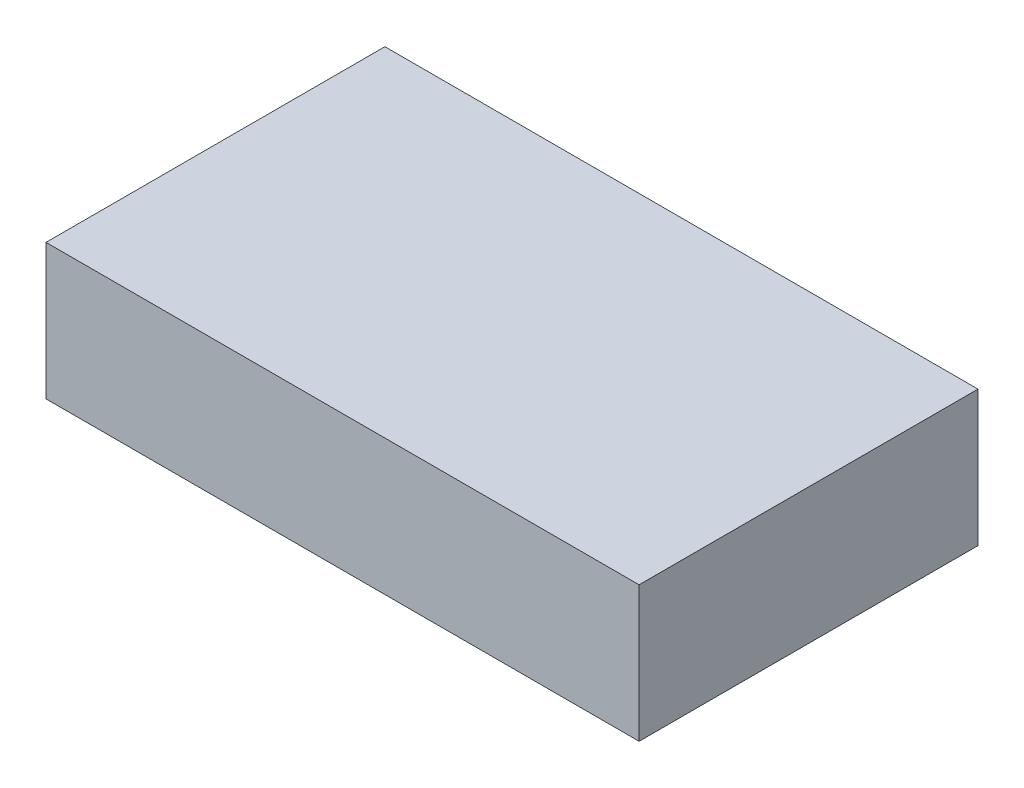
from build123d import *

# Parameters (mm, degrees)
SKETCH1_W           = 35
SKETCH1_H           = 20
BOSS_EXTRUDE1_DEPTH = 4


with BuildPart() as part:
    # Sketch1 → Boss-Extrude1 (new body, symmetric)
    with BuildSketch(Plane(origin=(0, 0, 0), x_dir=(1, 0, 0), z_dir=(0, 1, 0))):
        Rectangle(SKETCH1_W, SKETCH1_H)
    extrude(amount=BOSS_EXTRUDE1_DEPTH, both=True)


solid = part.part
